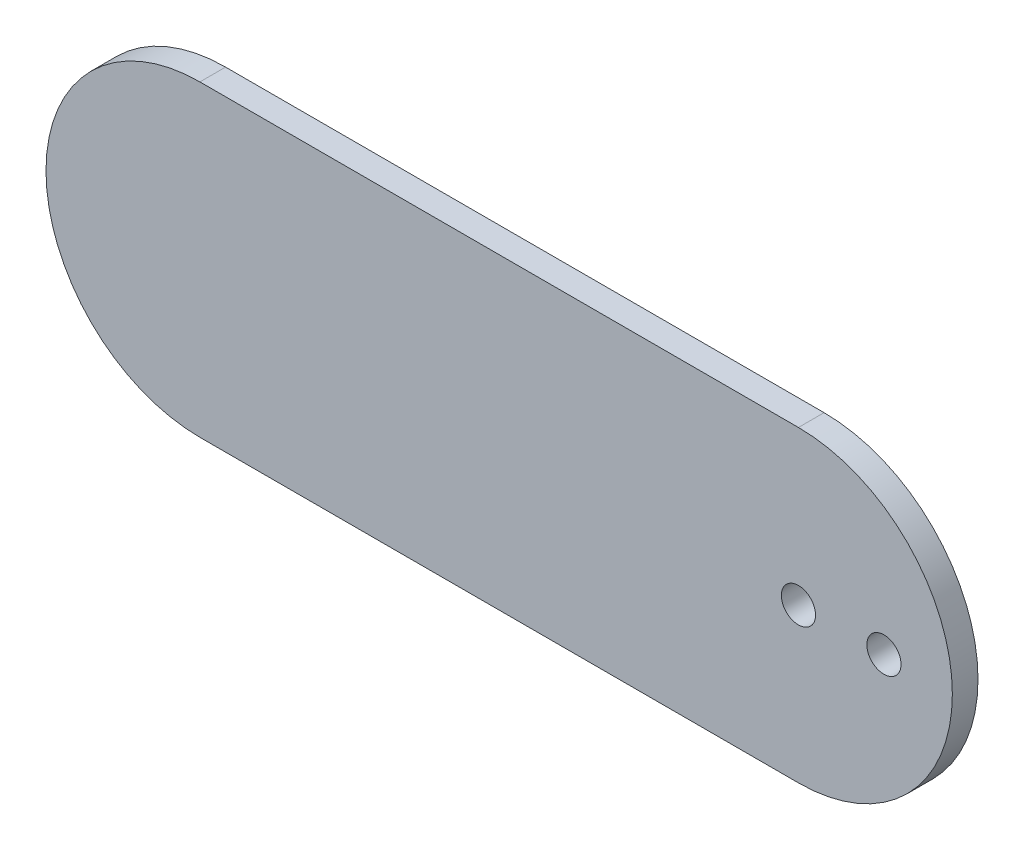
from build123d import *

# Parameters (mm, degrees)
SKETCH1_R           = 2
BOSS_EXTRUDE1_DEPTH = 3
SKETCH3_R           = 2
CUT_EXTRUDE1_DEPTH  = 3


with BuildPart() as part:
    # Sketch1 → Boss-Extrude1 (new body)
    with BuildSketch(Plane.XY):
        with BuildLine():
            Line((0, 18), (-70, 18))
            ThreePointArc((-70, 18), (-88, 0), (-70, -18))
            Line((-70, -18), (0, -18))
            ThreePointArc((0, -18), (18, 0), (0, 18))
        make_face()
        Circle(SKETCH1_R, mode=Mode.SUBTRACT)
    extrude(amount=BOSS_EXTRUDE1_DEPTH)

    # Sketch3 → Cut-Extrude1 (cut)
    with BuildSketch(Plane.XY.offset(3)):
        with Locations((10, 0)):
            Circle(SKETCH3_R)
    extrude(amount=-CUT_EXTRUDE1_DEPTH, mode=Mode.SUBTRACT)


solid = part.part
